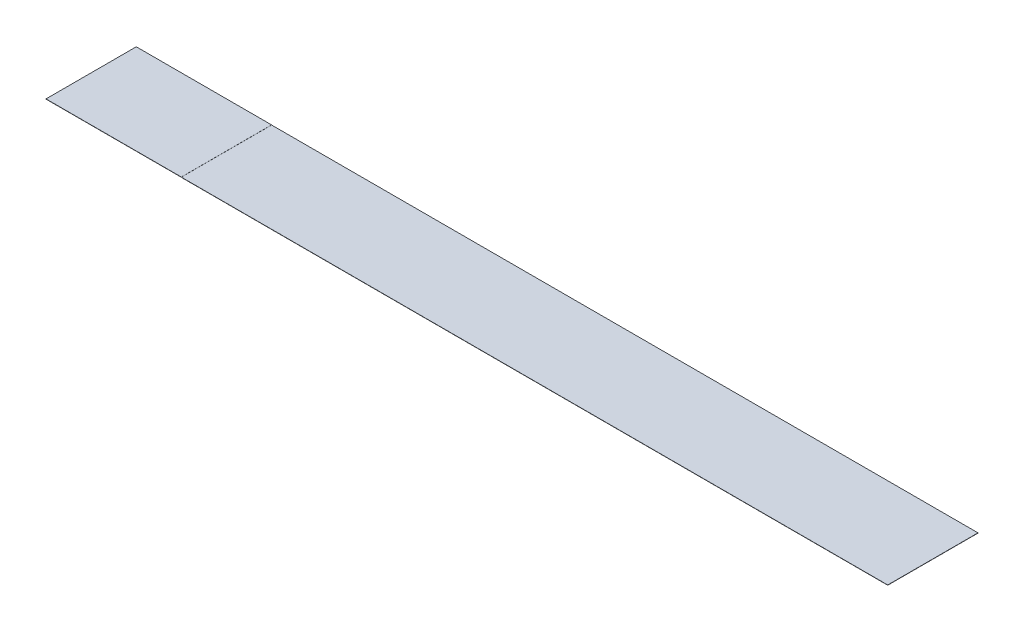
from build123d import *

# Parameters (mm, degrees)
SKETCH1_W           = 528.8
SKETCH1_H           = 61
EXTRUDE1_DEPTH      = 0.15
SKETCH3_W           = 20
SKETCH3_H           = 61
BOSS_EXTRUDE2_DEPTH = 0.15
SKETCH5_W           = 91.45
SKETCH5_H           = 0.06858
BOSS_EXTRUDE4_DEPTH = 61
SKETCH6_W           = 91.45
SKETCH6_H           = 0.06858
CUT_EXTRUDE1_DEPTH  = 62


with BuildPart() as part:
    # Sketch1 → Extrude1 (new body)
    with BuildSketch(Plane(origin=(0, 0, 0), x_dir=(1, 0, 0), z_dir=(0, 1, 0))):
        Rectangle(SKETCH1_W, SKETCH1_H)
    extrude(amount=EXTRUDE1_DEPTH)

    # Sketch3 → Boss-Extrude2 (add)
    with BuildSketch(Plane(origin=(0, 0.15, 0), x_dir=(1, 0, 0), z_dir=(0, 1, 0))):
        with Locations((-274.4, 0)):
            Rectangle(SKETCH3_W, SKETCH3_H)
        with Locations((274.4, 0)):
            Rectangle(SKETCH3_W, SKETCH3_H)
    extrude(amount=-BOSS_EXTRUDE2_DEPTH)

    # Sketch5 → Boss-Extrude4 (add)
    with BuildSketch(Plane.XY.offset(30.5)):
        with Locations((-238.675, 0.18429)):
            Rectangle(SKETCH5_W, SKETCH5_H)
    extrude(amount=-BOSS_EXTRUDE4_DEPTH)

    # Sketch6 → Cut-Extrude1 (cut, through all)
    with BuildSketch(Plane.XY.offset(30.5)):
        with Locations((-238.675, 0.03429)):
            Rectangle(SKETCH6_W, SKETCH6_H)
    extrude(amount=-CUT_EXTRUDE1_DEPTH, mode=Mode.SUBTRACT)


solid = part.part
